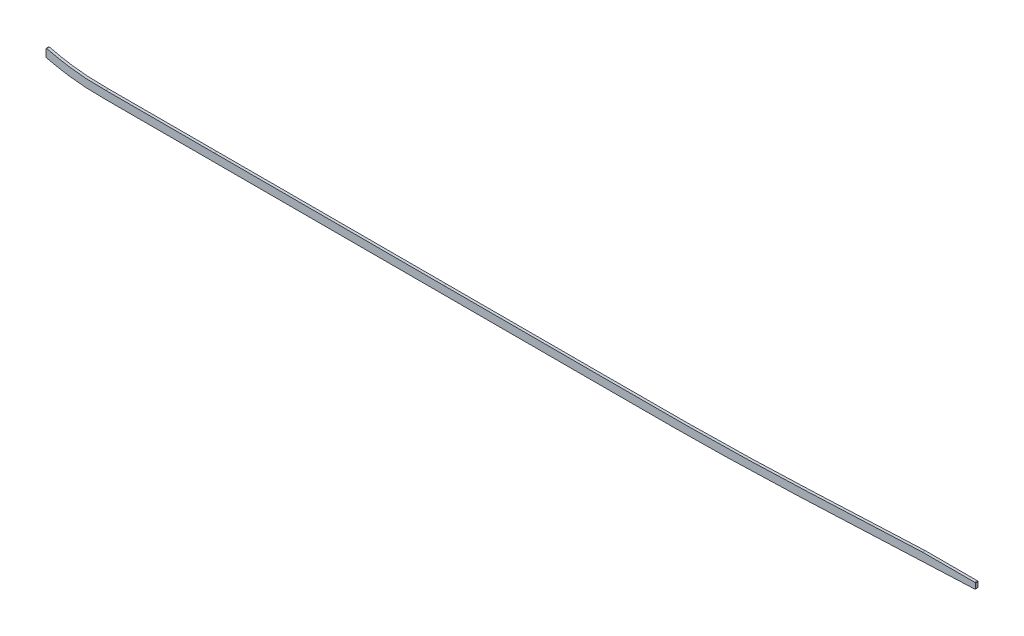
from build123d import *

# Parameters (mm, degrees)
BOSS_EXTRUDE1_DEPTH = 3.175
CUT_EXTRUDE1_DEPTH  = 7.3500001
FILLET1_R           = 1.27


with BuildPart() as part:
    # Sketch1 → Boss-Extrude1 (new body, symmetric)
    with BuildSketch(Plane.XY):
        with BuildLine():
            Line((499.61002795, -53.470702797), (1046.28548189, -53.470702797))
            add(Edge.make_bspline(
                [(2669.54, -9.569049356), (2615.393603553, -13.17073937), (2561.080658619, -16.536108081), (2506.205230446, -19.758621957), (2430.209106802, -23.505211705), (2354.212983157, -26.631486423), (2332.570330468, -27.480988169), (2156.268639429, -34.377768543), (1979.966947376, -41.628631248), (1824.114277635, -52.771265877), (1636.928606778, -53.579569849), (1449.742935921, -53.454024613), (1418.006730935, -53.470702797), (1324.899336146, -53.470702797), (1231.791940344, -53.470702797), (1170.441269319, -53.470702797), (1108.784075813, -53.470702797), (1047.126882346, -53.470702797), (1046.846414188, -53.470702797), (1046.565947184, -53.470702797), (1046.28548189, -53.470702797)],
                knots=[103.698913506, 103.698913506, 103.698913506, 103.698913506, 103.698913506, 103.698913506, 130.927896619, 130.927896619, 130.927896619, 141.337054719, 141.337054719, 141.337054719, 218.101815019, 218.101815019, 218.101815019, 233.772059419, 233.772059419, 233.772059419, 264.077723219, 264.077723219, 264.077723219, 264.2162088, 264.2162088, 264.2162088, 264.2162088, 264.2162088, 264.2162088], degree=5))
            Line((2669.54, -9.569049356), (2669.54, 9.5231025))
            add(Edge.make_bspline(
                [(2669.54, 9.5231025), (2667.126494524, 9.36235515), (2659.861586685, 8.880281494), (2635.666282302, 7.292469146), (2596.857665529, 4.826056853), (2545.729743039, 1.758344093), (2494.405305707, -1.098555235), (2451.533022267, -3.266573297), (2417.198316756, -4.86708361), (2391.457076919, -6.003589235), (2365.634736307, -7.086854581), (2339.546284672, -8.137729944), (2313.466132974, -9.165138371), (2287.612375486, -10.179478215), (2261.763347437, -11.201032297), (2227.285329715, -12.583842557), (2184.175569393, -14.36607236), (2132.429066114, -16.607427868), (2063.4255234, -19.708920485), (1977.174907635, -23.700543313), (1873.732451432, -28.149389221), (1770.37461881, -31.657468649), (1667.085687813, -33.793117556), (1581.011094491, -34.383188831), (1512.07397126, -34.4278026), (1443.061513477, -34.409510402), (1356.800927879, -34.424432812), (1218.794626954, -34.418464788), (1115.289022786, -34.420702797), (1046.28548189, -34.420702797)],
                knots=[103.571582669, 103.571582669, 103.571582669, 103.571582669, 104.300777207, 105.766098403, 110.877392287, 115.98868617, 121.099980054, 126.211273938, 128.76692088, 131.322567822, 133.878214764, 136.433861706, 138.989508647, 141.545155589, 144.100802531, 146.656449473, 151.767743357, 156.879037241, 161.990331124, 172.212918892, 182.43550666, 192.658094427, 202.880682195, 213.103269962, 218.214563846, 223.32585773, 233.548445497, 243.771033265, 264.2162088, 264.2162088, 264.2162088, 264.2162088], degree=3))
            Line((1046.28548189, -34.420702797), (499.61002795, -34.420702797))
            add(Edge.make_bspline(
                [(499.61002795, -34.420702797), (488.614737518, -34.420702797), (472.236395365, -34.420702798), (449.940231846, -34.420702794), (427.771305695, -34.42070281), (405.874681663, -34.420702712), (384.584909128, -34.420702942), (368.900229326, -34.420702244), (353.376568613, -34.420704862), (332.608466435, -34.420689186), (306.287754853, -34.420570006), (274.023487704, -34.420538256), (252.271015965, -34.420709741), (241.425150134, -34.420702761)],
                knots=[19.90682951, 19.90682951, 19.90682951, 19.90682951, 23.220120017, 24.876765271, 26.533410525, 29.846701033, 31.503346286, 33.15999154, 34.816636794, 36.473282048, 39.786572556, 43.099863063, 46.413153571, 46.413153571, 46.413153571, 46.413153571], degree=3))
            add(Edge.make_bspline(
                [(241.425150134, -34.420702761), (239.394928853, -34.420701455), (235.322322927, -34.420495867), (227.274423443, -34.398702533), (217.319360062, -34.297466855), (205.530690077, -33.976385563), (189.963341914, -33.212641271), (170.696984653, -31.543495194), (147.533261232, -28.314398128), (125.482753206, -24.202109872), (109.358914834, -20.622537553), (100.964116069, -18.612521054), (99.06, -18.149327722)],
                knots=[0, 0, 0, 0, 0.622088422, 1.244176844, 2.488353689, 3.732530533, 4.976707377, 7.465061066, 9.953414755, 12.441768444, 14.55823542, 15.180323842, 15.180323842, 15.180323842, 15.180323842], degree=3))
            Line((99.06, -18.149327722), (99.06, -37.741485304))
            add(Edge.make_bspline(
                [(241.425137875, -53.470702761), (224.286916993, -53.470691732), (207.149474967, -53.467315374), (190.203897513, -52.686577078), (161.734965878, -49.987457476), (133.266034188, -45.175583375), (121.749620566, -42.910592695), (110.349390726, -40.420274627), (99.06, -37.741485304)],
                knots=[0, 0, 0, 0, 0, 0, 8.71381608, 8.71381608, 8.71381608, 14.701907176, 14.701907176, 14.701907176, 14.701907176, 14.701907176, 14.701907176], degree=5))
            add(Edge.make_bspline(
                [(499.61002795, -53.470702797), (492.136820835, -53.470702797), (484.754348064, -53.470702797), (477.443025859, -53.470702797), (448.516583145, -53.470702797), (419.590140517, -53.470702797), (398.368118521, -53.470702797), (355.647540186, -53.470702797), (312.926961851, -53.470702797), (289.235090436, -53.470293029), (265.364963651, -53.470705034), (241.4948369, -53.470702789), (241.471603891, -53.470702785), (241.448370882, -53.470702776), (241.425137875, -53.470702761)],
                knots=[19.90682951, 19.90682951, 19.90682951, 19.90682951, 19.90682951, 19.90682951, 23.637897311, 23.637897311, 23.637897311, 34.276545571, 34.276545571, 34.276545571, 46.401340901, 46.401340901, 46.401340901, 46.413153571, 46.413153571, 46.413153571, 46.413153571, 46.413153571, 46.413153571], degree=5))
        make_face()
    extrude(amount=BOSS_EXTRUDE1_DEPTH, both=True)

    # Sketch2 → Cut-Extrude1 (cut, through all)
    with BuildSketch(Plane.XY.offset(3.175)):
        with BuildLine():
            add(Edge.make_bspline(
                [(2311.4, -9.245659725), (2303.45127581, -9.558066869), (2286.914031668, -10.207076776), (2261.763347437, -11.201032297), (2227.738431725, -12.565669989), (2202.325932618, -13.615715702), (2185.532985525, -14.325659725)],
                knots=[139.196640642, 139.196640642, 139.196640642, 139.196640642, 141.545155589, 144.100802531, 146.656449473, 151.63340051, 151.63340051, 151.63340051, 151.63340051], degree=3))
            Line((2185.532985525, -14.325659725), (2311.4, -14.325659725))
            Line((2311.4, -14.325659725), (2311.4, -9.245659725))
        make_face()
        with BuildLine():
            Line((2311.4, -9.245659725), (2311.4, -14.325659725))
            Line((2311.4, -14.325659725), (2311.4, -28.310356345))
            add(Edge.make_bspline(
                [(2669.54, -9.569049356), (2615.393603553, -13.17073937), (2561.080658619, -16.536108081), (2506.205230446, -19.758621957), (2434.382223772, -23.29947809), (2362.559217098, -26.286274493), (2345.393069943, -26.972929947), (2328.342945407, -27.644579597), (2311.4, -28.310356345)],
                knots=[103.698913506, 103.698913506, 103.698913506, 103.698913506, 103.698913506, 103.698913506, 130.927896619, 130.927896619, 130.927896619, 139.270260279, 139.270260279, 139.270260279, 139.270260279, 139.270260279, 139.270260279], degree=5))
            Line((2669.54, -9.569049356), (2669.54, 9.5231025))
            add(Edge.make_bspline(
                [(2669.54, 9.5231025), (2667.126494524, 9.36235515), (2659.861586685, 8.880281494), (2635.666282302, 7.292469146), (2596.857665529, 4.826056853), (2545.729743039, 1.758344093), (2494.405305707, -1.098555235), (2451.533022267, -3.266573297), (2417.198316756, -4.86708361), (2391.457076919, -6.003589235), (2365.634736307, -7.086854581), (2339.546284672, -8.137729944), (2321.454928961, -8.850425619), (2312.1010537, -9.218106349), (2311.4, -9.245659725)],
                knots=[103.571582669, 103.571582669, 103.571582669, 103.571582669, 104.300777207, 105.766098403, 110.877392287, 115.98868617, 121.099980054, 126.211273938, 128.76692088, 131.322567822, 133.878214764, 136.433861706, 138.989508647, 139.196640642, 139.196640642, 139.196640642, 139.196640642], degree=3))
        make_face()
    extrude(amount=-CUT_EXTRUDE1_DEPTH, mode=Mode.SUBTRACT)

    # Fillet1
    fillet1_edges = [part.edges().sort_by_distance(p)[0] for p in [
        (99.06, -37.741485304, -1.5875),
        (99.06, -18.149327722, -1.5875),
        (2311.4, -14.325659725, 0),
        (2311.4, -28.310356345, -1.5875),
    ]]
    fillet(fillet1_edges, radius=FILLET1_R)


solid = part.part
